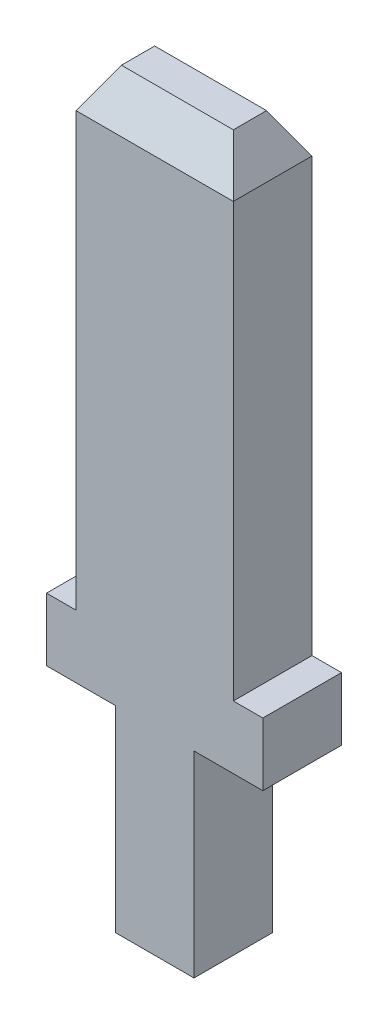
from build123d import *

# Parameters (mm, degrees)
EXTRUDE_1_DEPTH        = 1
CHAMFER_1_SIZE         = 1
CHAMFER_1_SIZE2        = 0.577350269
CHAMFER_1_PART_2_SIZE  = 1
CHAMFER_1_PART_2_SIZE2 = 0.577350269
CHAMFER_1_PART_3_SIZE  = 1
CHAMFER_1_PART_3_SIZE2 = 0.577350269
CHAMFER_1_PART_4_SIZE  = 1
CHAMFER_1_PART_4_SIZE2 = 0.577350269


with BuildPart() as part:
    # Эскиз1 → Бобышка-Вытянуть1 (new body, symmetric)
    with BuildSketch(Plane.XY):
        Polygon((1, 0), (-1, 0), (-1, 5), (-2.75, 5), (-2.75, 6.6), (-2, 6.6), (-2, 18.6), (2, 18.6), (2, 6.6), (2.75, 6.6), (2.75, 5), (1, 5), align=None)
    extrude(amount=EXTRUDE_1_DEPTH, both=True)

    # Фаска1
    chamfer_1_edges = [part.edges().sort_by_distance(p)[0] for p in [
        (0, 18.6, -1),
    ]]
    chamfer_1_side = [part.faces().sort_by_distance(p)[0] for p in [
        (0, 10.192215569, -1),
    ]]
    chamfer(chamfer_1_edges, length=CHAMFER_1_SIZE, length2=CHAMFER_1_SIZE2, reference=chamfer_1_side[0])

    # Фаска1 part 2
    chamfer_1_part_2_edges = [part.edges().sort_by_distance(p)[0] for p in [
        (-2, 18.6, 0),
    ]]
    chamfer_1_part_2_side = [part.faces().sort_by_distance(p)[0] for p in [
        (-2, 12.6, 0),
    ]]
    chamfer(chamfer_1_part_2_edges, length=CHAMFER_1_PART_2_SIZE, length2=CHAMFER_1_PART_2_SIZE2, reference=chamfer_1_part_2_side[0])

    # Фаска1 part 3
    chamfer_1_part_3_edges = [part.edges().sort_by_distance(p)[0] for p in [
        (2, 18.6, 0),
    ]]
    chamfer_1_part_3_side = [part.faces().sort_by_distance(p)[0] for p in [
        (2, 12.6, 0),
    ]]
    chamfer(chamfer_1_part_3_edges, length=CHAMFER_1_PART_3_SIZE, length2=CHAMFER_1_PART_3_SIZE2, reference=chamfer_1_part_3_side[0])

    # Фаска1 part 4
    chamfer_1_part_4_edges = [part.edges().sort_by_distance(p)[0] for p in [
        (0, 18.6, 1),
    ]]
    chamfer_1_part_4_side = [part.faces().sort_by_distance(p)[0] for p in [
        (0, 10.192215569, 1),
    ]]
    chamfer(chamfer_1_part_4_edges, length=CHAMFER_1_PART_4_SIZE, length2=CHAMFER_1_PART_4_SIZE2, reference=chamfer_1_part_4_side[0])


solid = part.part
